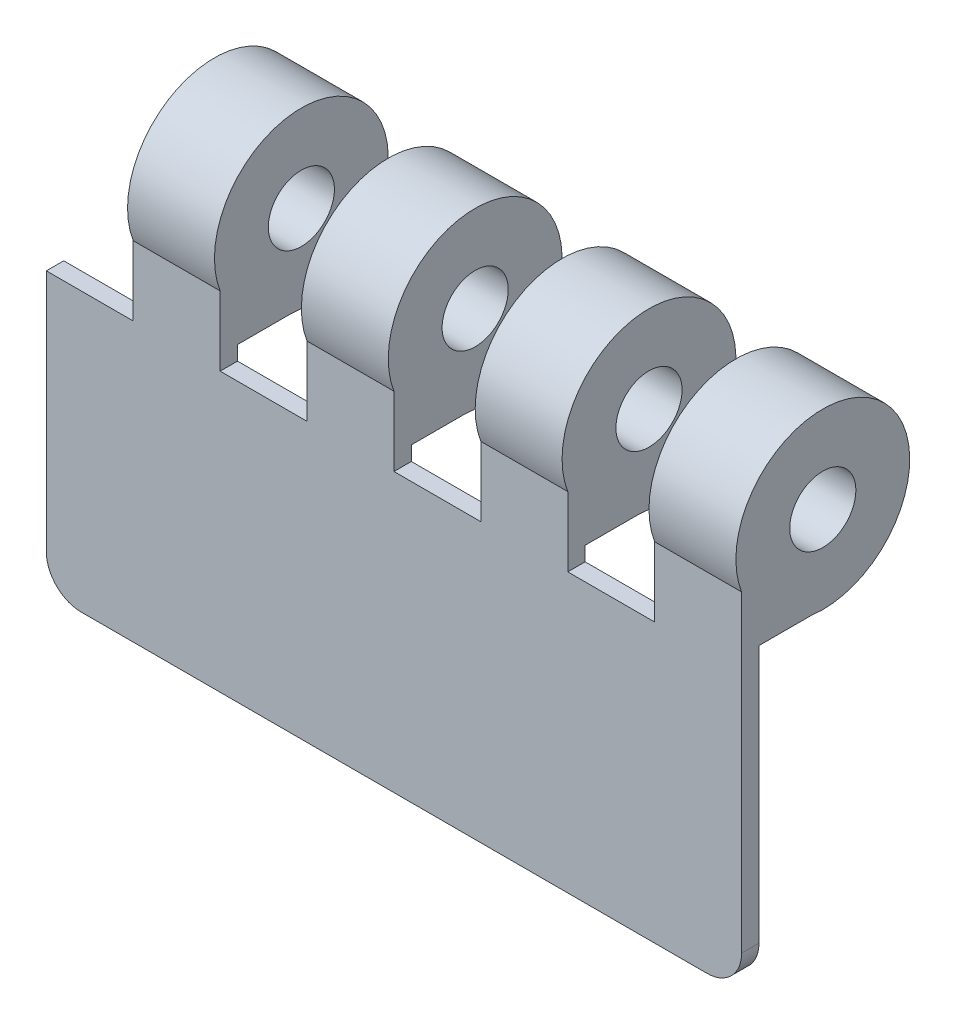
from build123d import *

# Parameters (mm, degrees)
SKETCH1_W           = 50.8
SKETCH1_H           = 25.4
BOSS_EXTRUDE1_DEPTH = 5.08
SKETCH2_R           = 6.35
BOSS_EXTRUDE5_DEPTH = 6.35
LPATTERN2_COUNT     = 4
LPATTERN2_PITCH     = 12.7
SKETCH7_W           = 6.35
SKETCH7_H           = 5.08
CUT_EXTRUDE2_DEPTH  = 5.08
CUT_EXTRUDE3_DEPTH  = 3.81
FILLET1_R           = 2.54
SKETCH2_5_R         = 2.416788658
CUT_EXTRUDE6_DEPTH  = 76.2


with BuildPart() as part:
    # Sketch1 → Boss-Extrude1 (new body)
    with BuildSketch(Plane.XY):
        Rectangle(SKETCH1_W, SKETCH1_H)
    extrude(amount=BOSS_EXTRUDE1_DEPTH)

    # Sketch2 → Boss-Extrude5 (add)
    with BuildSketch(Plane(origin=(25.4, 0, 0), x_dir=(0, 0, -1), z_dir=(1, 0, 0))):
        with Locations((0.853861474, 14.960926359)):
            Circle(SKETCH2_R)
    boss_extrude5 = extrude(amount=-BOSS_EXTRUDE5_DEPTH)

    # LPattern2: Boss-Extrude5 ×4
    with Locations(*[(-i * LPATTERN2_PITCH, 0, 0) for i in range(1, LPATTERN2_COUNT)]):
        add(boss_extrude5)

    # Sketch7 → Cut-Extrude2 (cut)
    with BuildSketch(Plane(origin=(0, 12.7, 0), x_dir=(1, 0, 0), z_dir=(0, 1, 0))):
        with Locations((15.875, -2.54)):
            Rectangle(SKETCH7_W, SKETCH7_H)
        with Locations((3.175, -2.54)):
            Rectangle(SKETCH7_W, SKETCH7_H)
        with Locations((-9.525, -2.54)):
            Rectangle(SKETCH7_W, SKETCH7_H)
        with Locations((-22.225, -2.54)):
            Rectangle(SKETCH7_W, SKETCH7_H)
    extrude(amount=-CUT_EXTRUDE2_DEPTH, mode=Mode.SUBTRACT)

    # Sketch8 → Cut-Extrude3 (cut)
    with BuildSketch(Plane(origin=(0, 0, 0), x_dir=(-1, 0, 0), z_dir=(0, 0, -1))):
        Polygon((-19.05, 7.62), (-19.05, 8.668596061), (-25.4, 8.668596061), (-25.4, -12.7), (25.4, -12.7), (25.4, 7.62), (19.05, 7.62), (19.05, 8.668596061), (12.7, 8.668596061), (12.7, 7.62), (6.35, 7.62), (6.35, 8.668596061), (0, 8.668596061), (0, 7.62), (-6.35, 7.62), (-6.35, 8.668596061), (-12.7, 8.668596061), (-12.7, 7.62), align=None)
    extrude(amount=-CUT_EXTRUDE3_DEPTH, mode=Mode.SUBTRACT)

    # Fillet1
    fillet1_edges = [part.edges().sort_by_distance(p)[0] for p in [
        (-25.4, -12.7, 4.445),
        (25.4, -12.7, 4.445),
    ]]
    fillet(fillet1_edges, radius=FILLET1_R)

    # Sketch2_5 → Cut-Extrude6 (cut)
    with BuildSketch(Plane(origin=(25.4, 0, 0), x_dir=(0, 0, -1), z_dir=(1, 0, 0))):
        with Locations((0.853861474, 14.960926359)):
            Circle(SKETCH2_5_R)
    extrude(amount=-CUT_EXTRUDE6_DEPTH, mode=Mode.SUBTRACT)


solid = part.part
